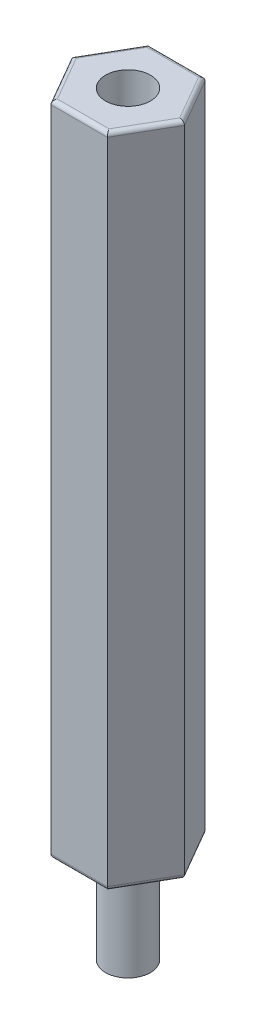
from build123d import *

# Parameters (mm, degrees)
RESSALTO_EXTRUS_O1_DEPTH = 32
FILETE1_R                = 0.2
ESBO_O2_R                = 1.0922
RESSALTO_EXTRUS_O2_DEPTH = 4.76
ESBO_O3_R                = 1.0922
CORTE_EXTRUS_O1_DEPTH    = 4.76


with BuildPart() as part:
    # Esboço1 → Ressalto-extrusão1 (new body)
    with BuildSketch(Plane(origin=(0, 0, 0), x_dir=(1, 0, 0), z_dir=(0, 1, 0))):
        Polygon((2.748187281, 0), (1.374093641, 2.38), (-1.374093641, 2.38), (-2.748187281, 0), (-1.374093641, -2.38), (1.374093641, -2.38), align=None)
    extrude(amount=RESSALTO_EXTRUS_O1_DEPTH)

    # Filete1
    filete1_edges = [part.edges().sort_by_distance(p)[0] for p in [
        (0, 32, -2.38),
        (-2.061140461, 32, -1.19),
        (-2.061140461, 32, 1.19),
        (0, 32, 2.38),
        (2.061140461, 32, 1.19),
        (0, 0, 2.38),
        (-2.061140461, 0, 1.19),
        (-2.061140461, 0, -1.19),
        (2.061140461, 32, -1.19),
        (0, 0, -2.38),
        (2.061140461, 0, -1.19),
        (2.061140461, 0, 1.19),
    ]]
    fillet(filete1_edges, radius=FILETE1_R)

    # Esboço2 → Ressalto-extrusão2 (add)
    with BuildSketch(Plane.XZ):
        Circle(ESBO_O2_R)
    extrude(amount=RESSALTO_EXTRUS_O2_DEPTH)

    # Esboço3 → Corte-extrusão1 (cut)
    with BuildSketch(Plane(origin=(0, 32, 0), x_dir=(1, 0, 0), z_dir=(0, 1, 0))):
        Circle(ESBO_O3_R)
    extrude(amount=-CORTE_EXTRUS_O1_DEPTH, mode=Mode.SUBTRACT)


solid = part.part
